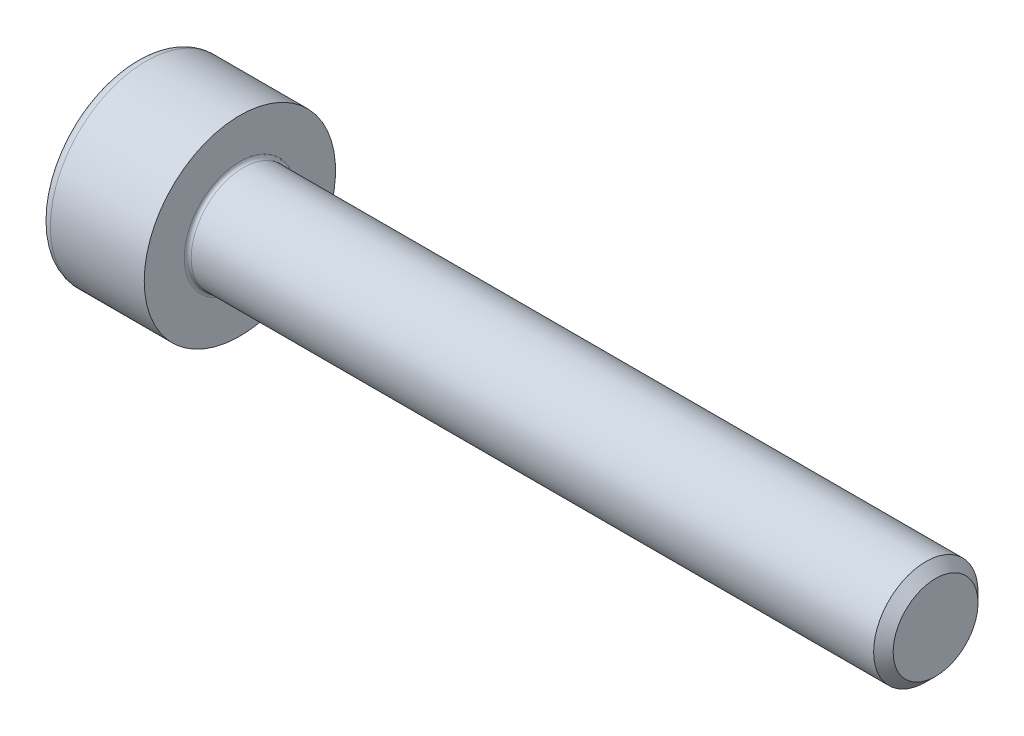
from build123d import *

# Parameters (mm, degrees)
FILLET1_R   = 0.1
FILLET2_R   = 0.3
HEX_2_DEPTH = 1.3


with BuildPart() as part:
    # BodySke → Base-Revolve (revolve)
    with BuildSketch(Plane.XY):
        Polygon((0, 0), (0, 2.75), (3, 2.75), (3, 1.5), (22.7195, 1.5), (23, 1.2195), (23, 0), align=None)
    revolve(axis=Axis((-31.75, 0, 0), (1, 0, 0)))

    # Fillet1
    fillet1_edges = [part.edges().sort_by_distance(p)[0] for p in [
        (3, -1.5, 0),
    ]]
    fillet(fillet1_edges, radius=FILLET1_R)

    # Fillet2
    fillet2_edges = [part.edges().sort_by_distance(p)[0] for p in [
        (0, -2.75, 0),
    ]]
    fillet(fillet2_edges, radius=FILLET2_R)

    # Sketch2 → Hex-PreBroach (revolve, cut)
    with BuildSketch(Plane.XY):
        Polygon((0, 1.26), (1.3, 1.26), (2.027461339, 0), (0, 0), align=None)
    revolve(axis=Axis((0, 0, 0), (1, 0, 0)), mode=Mode.SUBTRACT)

    # Sketch3 → Hex 2 (cut)
    with BuildSketch(Plane(origin=(0, 0, 0), x_dir=(0, 0.5, 0.866025404), z_dir=(-1, 0, 0))):
        Polygon((0.727461339, 1.26), (-0.727461339, 1.26), (-1.454922678, 0), (-0.727461339, -1.26), (0.727461339, -1.26), (1.454922678, 0), align=None)
    extrude(amount=-HEX_2_DEPTH, mode=Mode.SUBTRACT)


solid = part.part
